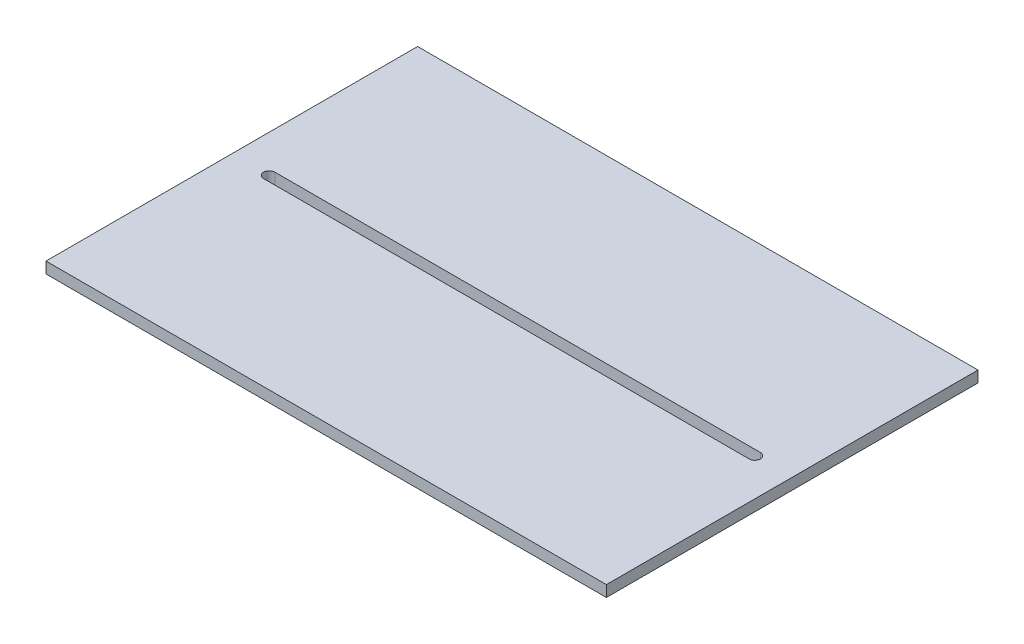
from build123d import *

# Parameters (mm, degrees)
SKETCH1_W           = 150
SKETCH1_H           = 99.477058683
BOSS_EXTRUDE1_DEPTH = 3


with BuildPart() as part:
    # Sketch1 → Boss-Extrude1 (new body)
    with BuildSketch(Plane(origin=(0, 0, 0), x_dir=(1, 0, 0), z_dir=(0, 1, 0))):
        with Locations((75, 49.738529342)):
            Rectangle(SKETCH1_W, SKETCH1_H)
        with BuildLine():
            Line((140, 48.238529342), (10, 48.238529342))
            ThreePointArc((10, 48.238529342), (8.5, 49.738529342), (10, 51.238529342))
            Line((10, 51.238529342), (140, 51.238529342))
            ThreePointArc((140, 51.238529342), (141.5, 49.738529342), (140, 48.238529342))
        make_face(mode=Mode.SUBTRACT)
    extrude(amount=BOSS_EXTRUDE1_DEPTH)


solid = part.part
